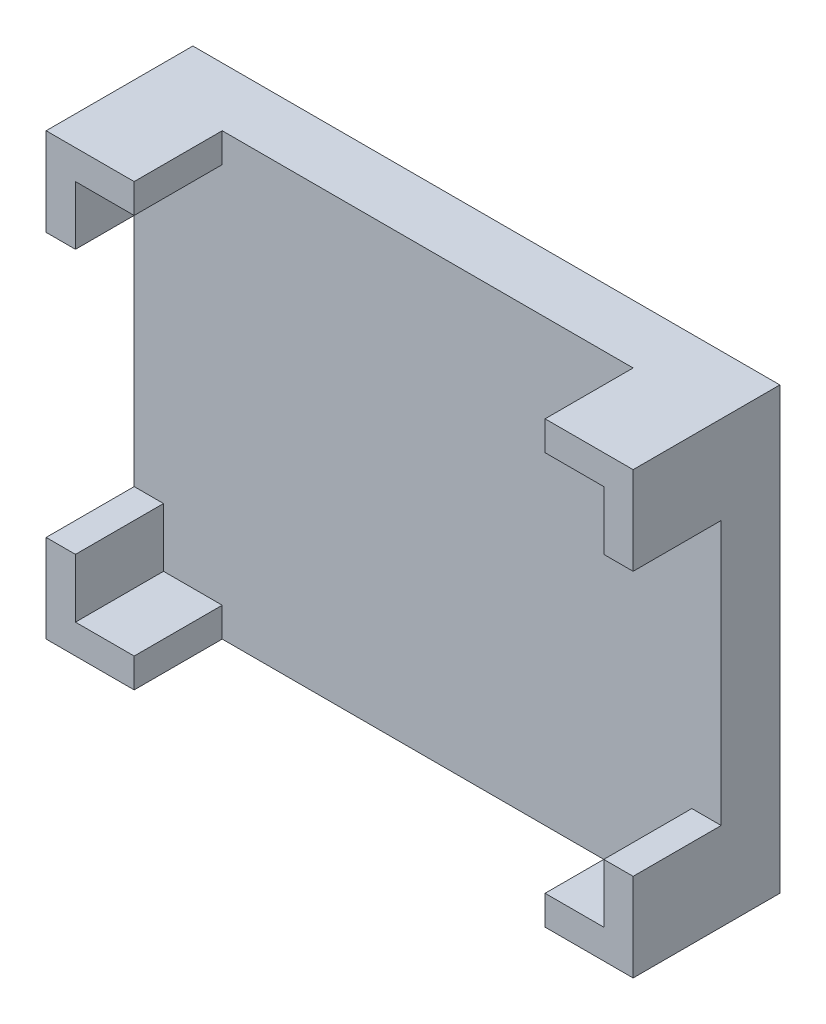
from build123d import *

# Parameters (mm, degrees)
SKETCH1_W           = 20
SKETCH1_H           = 15
BOSS_EXTRUDE2_DEPTH = 2
BOSS_EXTRUDE3_DEPTH = 3


with BuildPart() as part:
    # Sketch1 → Boss-Extrude2 (new body)
    with BuildSketch(Plane.XY):
        with Locations((10, 7.5)):
            Rectangle(SKETCH1_W, SKETCH1_H)
    extrude(amount=BOSS_EXTRUDE2_DEPTH)

    # Sketch2 → Boss-Extrude3 (add)
    with BuildSketch(Plane.XY.offset(2)):
        Polygon((1, 15), (0, 15), (0, 14), (0, 12), (1, 12), (1, 14), (3, 14), (3, 15), align=None)
        Polygon((1, 3), (0, 3), (0, 1), (0, 0), (1, 0), (3, 0), (3, 1), (1, 1), align=None)
        Polygon((19, 15), (17, 15), (17, 14), (19, 14), (19, 12), (20, 12), (20, 14), (20, 15), align=None)
        Polygon((20, 0), (17, 0), (17, 1), (19, 1), (19, 3), (20, 3), align=None)
    extrude(amount=BOSS_EXTRUDE3_DEPTH)


solid = part.part
